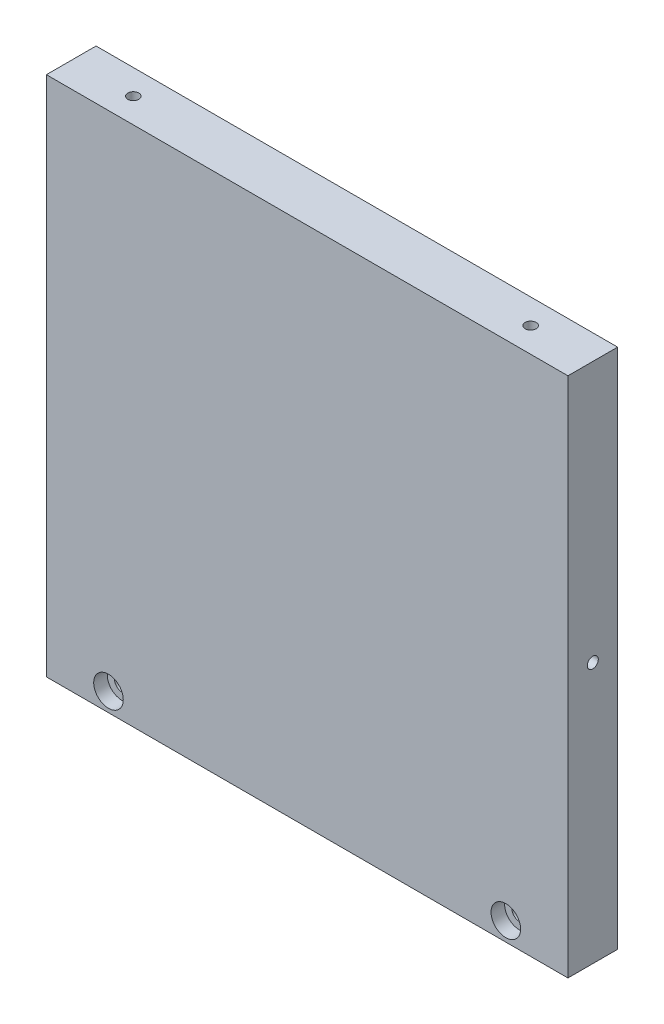
from build123d import *

# Parameters (mm, degrees)
SKETCH1_W                                      = 84
SKETCH1_H                                      = 84
BOSS_EXTRUDE1_DEPTH                            = 8
CBORE_FOR_2_SOCKET_HEAD_CAP_SCREW1_D           = 2.4384
CBORE_FOR_2_SOCKET_HEAD_CAP_SCREW1_DEPTH       = 8
CBORE_FOR_2_SOCKET_HEAD_CAP_SCREW1_CBORE_D     = 4.7625
CBORE_FOR_2_SOCKET_HEAD_CAP_SCREW1_CBORE_DEPTH = 2.1844
F_2_56_TAPPED_HOLE1_D                          = 1.778
F_2_56_TAPPED_HOLE1_DEPTH                      = 12
F_2_56_TAPPED_HOLE1_TIP                        = 0.53416509
F_2_56_TAPPED_HOLE2_D                          = 1.778
F_2_56_TAPPED_HOLE2_DEPTH                      = 12
F_2_56_TAPPED_HOLE2_TIP                        = 0.53416509
F_2_56_TAPPED_HOLE3_D                          = 1.778
F_2_56_TAPPED_HOLE3_DEPTH                      = 12
F_2_56_TAPPED_HOLE3_TIP                        = 0.53416509


with BuildPart() as part:
    # Sketch1 → Boss-Extrude1 (new body)
    with BuildSketch(Plane.XY):
        Rectangle(SKETCH1_W, SKETCH1_H)
    extrude(amount=BOSS_EXTRUDE1_DEPTH)

    # CBORE for #2 Socket Head Cap Screw1
    with Locations(Plane(origin=(-32, -39, 8), x_dir=(1, 0, 0), z_dir=(0, 0, 1))):
        with Locations((0, 0), (64, 0)):
            CounterBoreHole(CBORE_FOR_2_SOCKET_HEAD_CAP_SCREW1_D / 2, CBORE_FOR_2_SOCKET_HEAD_CAP_SCREW1_CBORE_D / 2, CBORE_FOR_2_SOCKET_HEAD_CAP_SCREW1_CBORE_DEPTH, depth=CBORE_FOR_2_SOCKET_HEAD_CAP_SCREW1_DEPTH)

    # #2-56 Tapped Hole1
    with Locations(Plane(origin=(42, 0, 4), x_dir=(0, 0, 1), z_dir=(1, 0, 0))):
        with Locations((0, 0)):
            Hole(F_2_56_TAPPED_HOLE1_D / 2, depth=F_2_56_TAPPED_HOLE1_DEPTH)
            with Locations((0, 0, -(F_2_56_TAPPED_HOLE1_DEPTH + F_2_56_TAPPED_HOLE1_TIP / 2))):  # 118° drill point
                Cone(0, F_2_56_TAPPED_HOLE1_D / 2, F_2_56_TAPPED_HOLE1_TIP, mode=Mode.SUBTRACT)

    # #2-56 Tapped Hole2
    with Locations(Plane(origin=(-42, 0, 4), x_dir=(0, 0, -1), z_dir=(-1, 0, 0))):
        with Locations((0, 0)):
            Hole(F_2_56_TAPPED_HOLE2_D / 2, depth=F_2_56_TAPPED_HOLE2_DEPTH)
            with Locations((0, 0, -(F_2_56_TAPPED_HOLE2_DEPTH + F_2_56_TAPPED_HOLE2_TIP / 2))):  # 118° drill point
                Cone(0, F_2_56_TAPPED_HOLE2_D / 2, F_2_56_TAPPED_HOLE2_TIP, mode=Mode.SUBTRACT)

    # #2-56 Tapped Hole3
    with Locations(Plane(origin=(-32, 42, 4), x_dir=(0, 0, 1), z_dir=(0, 1, 0))):
        with Locations((0, 0), (0, 64)):
            Hole(F_2_56_TAPPED_HOLE3_D / 2, depth=F_2_56_TAPPED_HOLE3_DEPTH)
            with Locations((0, 0, -(F_2_56_TAPPED_HOLE3_DEPTH + F_2_56_TAPPED_HOLE3_TIP / 2))):  # 118° drill point
                Cone(0, F_2_56_TAPPED_HOLE3_D / 2, F_2_56_TAPPED_HOLE3_TIP, mode=Mode.SUBTRACT)


solid = part.part
